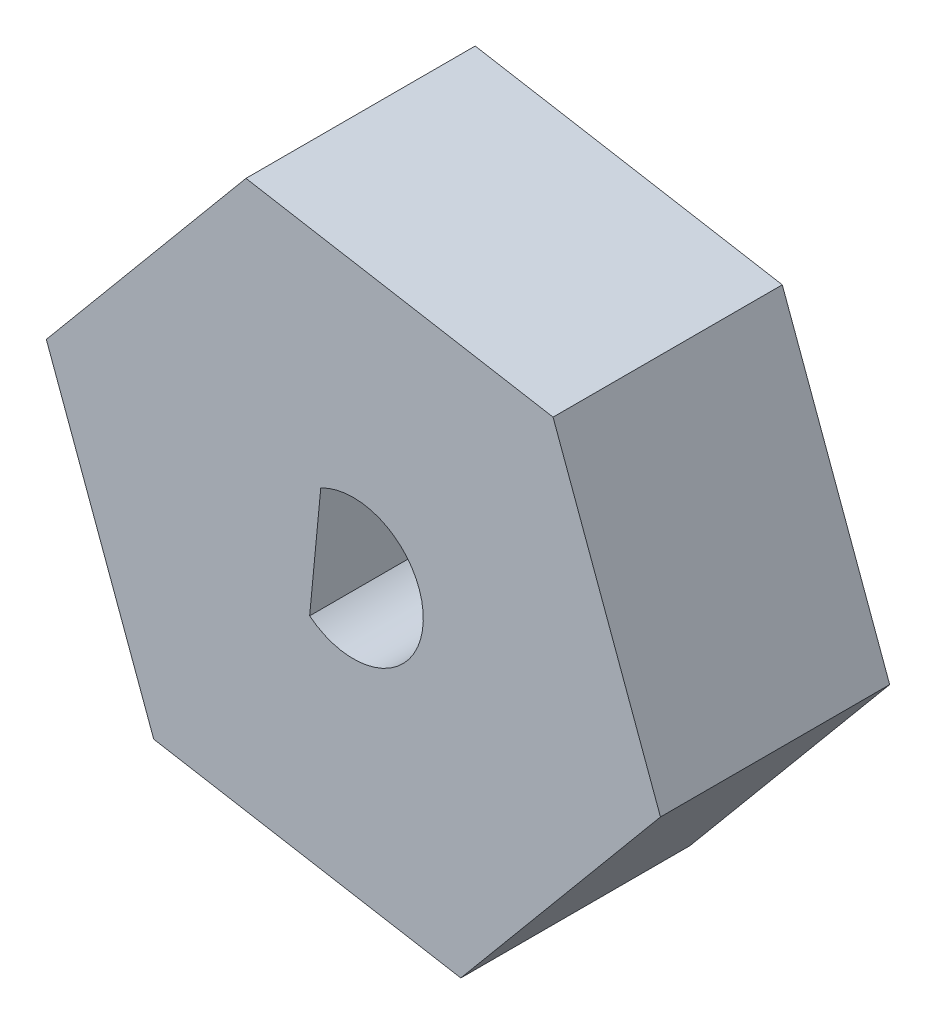
from build123d import *

# Parameters (mm, degrees)
BOSS_EXTRUDE2_DEPTH = 10


with BuildPart() as part:
    # Sketch1 → Boss-Extrude2 (new body)
    with BuildSketch(Plane.XY):
        Polygon((13.439595942, -2.441270434), (8.753924566, 10.322427453), (-4.642597738, 12.646365952), (-13.353448667, 2.206606563), (-8.667777292, -10.557091324), (4.728745013, -12.881029823), align=None)
        with BuildLine():
            Line((-1.865402523, -2.496453358), (-1.379890953, 2.580384094))
            ThreePointArc((-1.379890953, 2.580384094), (3.079221525, -0.407686894), (-1.865402523, -2.496453358))
        make_face(mode=Mode.SUBTRACT)
    extrude(amount=BOSS_EXTRUDE2_DEPTH)


solid = part.part
